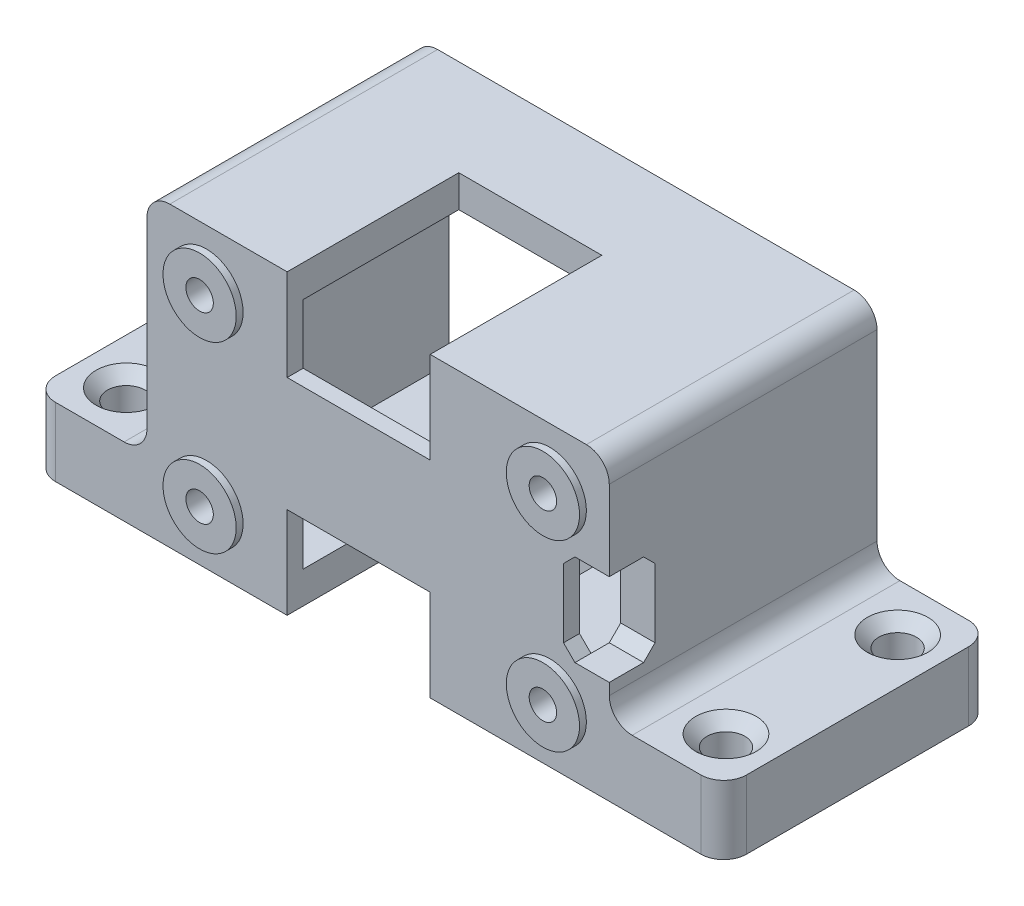
from build123d import *

# Parameters (mm, degrees)
SKETCH1_W           = 40.4
SKETCH1_H           = 26
SKETCH1_W_2         = 34.4
SKETCH1_H_2         = 20.4
BOSS_EXTRUDE1_DEPTH = 22
SKETCH2_W           = 40.4
SKETCH2_H           = 26
BOSS_EXTRUDE2_DEPTH = 1.4
SKETCH3_W           = 12.5
SKETCH3_H           = 8
CUT_EXTRUDE1_DEPTH  = 15
SKETCH4_R           = 1.2
CUT_EXTRUDE2_DEPTH  = 24.4
SKETCH5_W           = 10
SKETCH5_H           = 6
BOSS_EXTRUDE3_DEPTH = 23.4
FILLET1_R           = 2
SKETCH6_R           = 1.65
CUT_EXTRUDE3_DEPTH  = 7
CHAMFER1_SIZE       = 1
SKETCH8_W           = 4
SKETCH8_H           = 8
CUT_EXTRUDE4_DEPTH  = 4
CHAMFER2_SIZE       = 1
SKETCH9_R           = 3.2
SKETCH9_R_2         = 1.2
BOSS_EXTRUDE4_DEPTH = 0.6


with BuildPart() as part:
    # Sketch1 → Boss-Extrude1 (new body)
    with BuildSketch(Plane.XY):
        Rectangle(SKETCH1_W, SKETCH1_H)
        Rectangle(SKETCH1_W_2, SKETCH1_H_2, mode=Mode.SUBTRACT)
    extrude(amount=BOSS_EXTRUDE1_DEPTH)

    # Sketch2 → Boss-Extrude2 (add)
    with BuildSketch(Plane.XY.offset(22)):
        Rectangle(SKETCH2_W, SKETCH2_H)
    extrude(amount=BOSS_EXTRUDE2_DEPTH)

    # Sketch3 → Cut-Extrude1 (cut)
    with BuildSketch(Plane.XY.offset(23.4)):
        with Locations((-1.7, 9)):
            Rectangle(SKETCH3_W, SKETCH3_H)
        with Locations((-1.7, -9)):
            Rectangle(SKETCH3_W, SKETCH3_H)
    extrude(amount=-CUT_EXTRUDE1_DEPTH, mode=Mode.SUBTRACT)

    # Sketch4 → Cut-Extrude2 (cut, through all)
    with BuildSketch(Plane.XY.offset(23.4)):
        with Locations((-15, 8)):
            Circle(SKETCH4_R)
        with Locations((-15, -8)):
            Circle(SKETCH4_R)
        with Locations((15, 8)):
            Circle(SKETCH4_R)
        with Locations((15, -8)):
            Circle(SKETCH4_R)
    extrude(amount=-CUT_EXTRUDE2_DEPTH, mode=Mode.SUBTRACT)

    # Sketch5 → Boss-Extrude3 (add)
    with BuildSketch(Plane(origin=(0, 0, 0), x_dir=(-1, 0, 0), z_dir=(0, 0, -1))):
        with Locations((-25.2, -10)):
            Rectangle(SKETCH5_W, SKETCH5_H)
        with Locations((25.2, -10)):
            Rectangle(SKETCH5_W, SKETCH5_H)
    extrude(amount=-BOSS_EXTRUDE3_DEPTH)

    # Fillet1
    fillet1_edges = [part.edges().sort_by_distance(p)[0] for p in [
        (30.2, -10, 0),
        (30.2, -10, 23.4),
        (20.2, -7, 11.7),
        (-30.2, -10, 0),
        (-30.2, -10, 23.4),
        (-20.2, -7, 11.7),
        (-20.2, 13, 11.7),
        (20.2, 13, 11.7),
    ]]
    fillet(fillet1_edges, radius=FILLET1_R)

    # Sketch6 → Cut-Extrude3 (cut, through all)
    with BuildSketch(Plane(origin=(0, -7, 0), x_dir=(1, 0, 0), z_dir=(0, 1, 0))):
        with Locations((26.2, -4.2)):
            Circle(SKETCH6_R)
        with Locations((26.2, -19.2)):
            Circle(SKETCH6_R)
        with Locations((-26.2, -19.2)):
            Circle(SKETCH6_R)
        with Locations((-26.2, -4.2)):
            Circle(SKETCH6_R)
    extrude(amount=-CUT_EXTRUDE3_DEPTH, mode=Mode.SUBTRACT)

    # Chamfer1
    chamfer1_edges = [part.edges().sort_by_distance(p)[0] for p in [
        (-27.85, -7, 4.2),
        (-27.85, -7, 19.2),
        (24.55, -7, 19.2),
        (24.55, -7, 4.2),
    ]]
    chamfer(chamfer1_edges, length=CHAMFER1_SIZE)

    # Sketch8 → Cut-Extrude4 (cut)
    with BuildSketch(Plane.XY.offset(23.4)):
        with Locations((18.2, 0)):
            Rectangle(SKETCH8_W, SKETCH8_H)
    extrude(amount=-CUT_EXTRUDE4_DEPTH, mode=Mode.SUBTRACT)

    # Chamfer2
    chamfer2_edges = [part.edges().sort_by_distance(p)[0] for p in [
        (16.2, -4, 22.7),
        (16.2, 4, 22.7),
        (18.7, 4, 19.4),
        (18.7, -4, 19.4),
    ]]
    chamfer(chamfer2_edges, length=CHAMFER2_SIZE)

    # Sketch9 → Boss-Extrude4 (add)
    with BuildSketch(Plane.XY.offset(23.4)):
        with Locations((-15, 8)):
            Circle(SKETCH9_R)
        with Locations((-15, 8)):
            Circle(SKETCH9_R_2, mode=Mode.SUBTRACT)
        with Locations((-15, -8)):
            Circle(SKETCH9_R)
        with Locations((-15, -8)):
            Circle(SKETCH9_R_2, mode=Mode.SUBTRACT)
        with Locations((15, -8)):
            Circle(SKETCH9_R)
        with Locations((15, -8)):
            Circle(SKETCH9_R_2, mode=Mode.SUBTRACT)
        with Locations((15, 8)):
            Circle(SKETCH9_R)
        with Locations((15, 8)):
            Circle(SKETCH9_R_2, mode=Mode.SUBTRACT)
    extrude(amount=BOSS_EXTRUDE4_DEPTH)


solid = part.part
